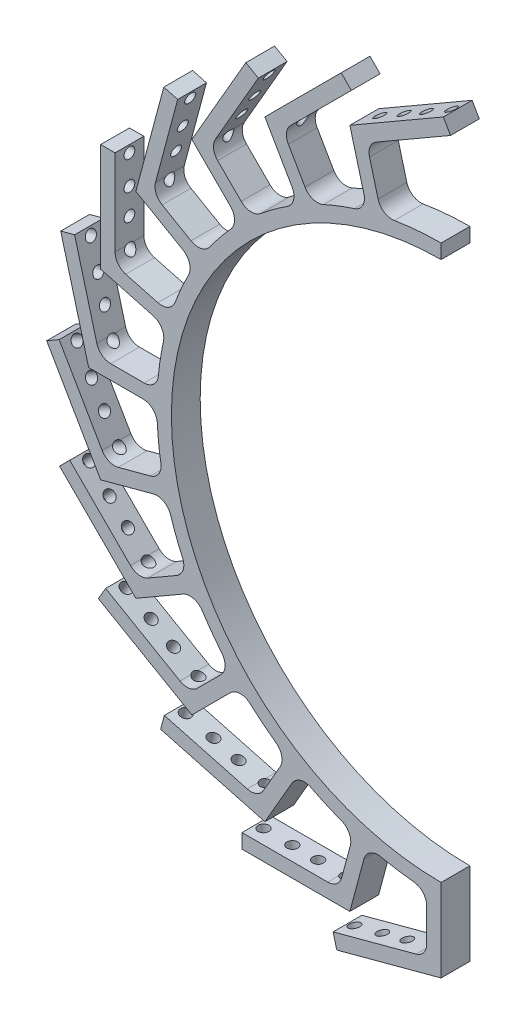
from build123d import *

# Parameters (mm, degrees)
BOSS_EXTRUDE1_DEPTH = 12.7
BOSS_EXTRUDE2_DEPTH = 12.7
FILLET1_R           = 6.35
CIRPATTERN1_COUNT   = 12
CIRPATTERN1_ANGLE   = 165
FILLET2_R           = 6.35
SKETCH3_R           = 2.38125
CUT_EXTRUDE1_DEPTH  = 12.7
CIRPATTERN8_COUNT   = 12
CIRPATTERN8_ANGLE   = 165


with BuildPart() as part:
    # Sketch1 → Boss-Extrude1 (new body)
    with BuildSketch(Plane.XY):
        with BuildLine():
            Line((0, -125.349), (0, -118.999))
            ThreePointArc((0, -118.999), (-118.999, 0), (0, 118.999))
            Line((0, 118.999), (0, 125.349))
            ThreePointArc((0, 125.349), (-125.349, 0), (0, -125.349))
        make_face()
    extrude(amount=BOSS_EXTRUDE1_DEPTH)

    # Sketch2 → Boss-Extrude2 (add)
    with BuildSketch(Plane.XY.offset(12.7)):
        with BuildLine():
            Line((0, -125.349), (0, -155.5115))
            Line((0, -155.5115), (-46.002217477, -167.837757023))
            Line((-46.002217477, -167.837757023), (-47.645718413, -161.704128026))
            Line((-47.645718413, -161.704128026), (-6.35, -150.638973626))
            Line((-6.35, -150.638973626), (-6.35, -125.188055744))
            ThreePointArc((-6.35, -125.188055744), (-3.176019642, -125.308757476), (0, -125.349))
        make_face()
    boss_extrude2 = extrude(amount=-BOSS_EXTRUDE2_DEPTH)

    # Fillet1
    fillet1_edges = [part.edges().sort_by_distance(p)[0] for p in [
        (-6.35, -125.188055744, 6.35),
        (-6.35, -150.638973626, 6.35),
    ]]
    fillet(fillet1_edges, radius=FILLET1_R)

    # CirPattern1: Boss-Extrude2 ×12 about axis
    cirpattern1_axis = Axis((0, 0, 0), (0, 0, -1))
    for i in range(1, CIRPATTERN1_COUNT):
        add(boss_extrude2.rotate(cirpattern1_axis, i * CIRPATTERN1_ANGLE / (CIRPATTERN1_COUNT - 1)))

    # Fillet2
    fillet2_edges = [part.edges().sort_by_distance(p)[0] for p in [
        (-122.565877123, -26.267424049, 6.35),
        (-121.0778364, -32.442708485, 6.35),
        (-147.149576008, -32.854606312, 6.35),
        (-125.188055744, 6.35, 6.35),
        (-125.349, 0, 6.35),
        (-150.638973626, 6.35, 6.35),
        (-119.27887525, 38.534682043, 6.35),
        (-121.0778364, 32.442708485, 6.35),
        (-143.862574135, 45.121864306, 6.35),
        (-105.241036525, 68.093289186, 6.35),
        (-108.555418339, 62.6745, 6.35),
        (-127.28217796, 80.818748127, 6.35),
        (-84.03119508, 93.011451201, 6.35),
        (-88.635127915, 88.635127915, 6.35),
        (-102.027711702, 111.007967823, 6.35),
        (-57.094766558, 111.591036525, 6.35),
        (-62.6745, 108.555418339, 6.35),
        (-69.820225499, 133.63217796, 6.35),
        (-26.267424049, 122.565877123, 6.35),
        (-32.442708485, 121.0778364, 6.35),
        (-32.854606312, 147.149576008, 6.35),
        (-38.534682043, -119.27887525, 6.35),
        (-32.442708485, -121.0778364, 6.35),
        (-45.121864306, -143.862574135, 6.35),
        (-68.093289186, -105.241036525, 6.35),
        (-62.6745, -108.555418339, 6.35),
        (-80.818748127, -127.28217796, 6.35),
        (-93.011451201, -84.03119508, 6.35),
        (-88.635127915, -88.635127915, 6.35),
        (-111.007967823, -102.027711702, 6.35),
        (-111.591036525, -57.094766558, 6.35),
        (-108.555418339, -62.6745, 6.35),
        (-133.63217796, -69.820225499, 6.35),
    ]]
    fillet(fillet2_edges, radius=FILLET2_R)

    # Sketch3 → Cut-Extrude1 (cut)
    with BuildSketch(Plane(origin=(38.877875, -145.09420479, 0), x_dir=(0.965925826, 0.258819045, 0), z_dir=(0.258819045, -0.965925826, 0))):
        with Locations((-48.186837932, 6.35)):
            Circle(SKETCH3_R)
        with Locations((-84.699337932, 6.35)):
            Circle(SKETCH3_R)
        with Locations((-60.569337932, 6.35)):
            Circle(SKETCH3_R)
        with Locations((-71.999337932, 6.35)):
            Circle(SKETCH3_R)
    cut_extrude1 = extrude(amount=-CUT_EXTRUDE1_DEPTH, mode=Mode.SUBTRACT)

    # CirPattern8: Cut-Extrude1 ×12 about axis
    cirpattern8_axis = Axis((0, 0, 12.7), (0, 0, -1))
    for i in range(1, CIRPATTERN8_COUNT):
        add(cut_extrude1.rotate(cirpattern8_axis, i * CIRPATTERN8_ANGLE / (CIRPATTERN8_COUNT - 1)), mode=Mode.SUBTRACT)


solid = part.part
